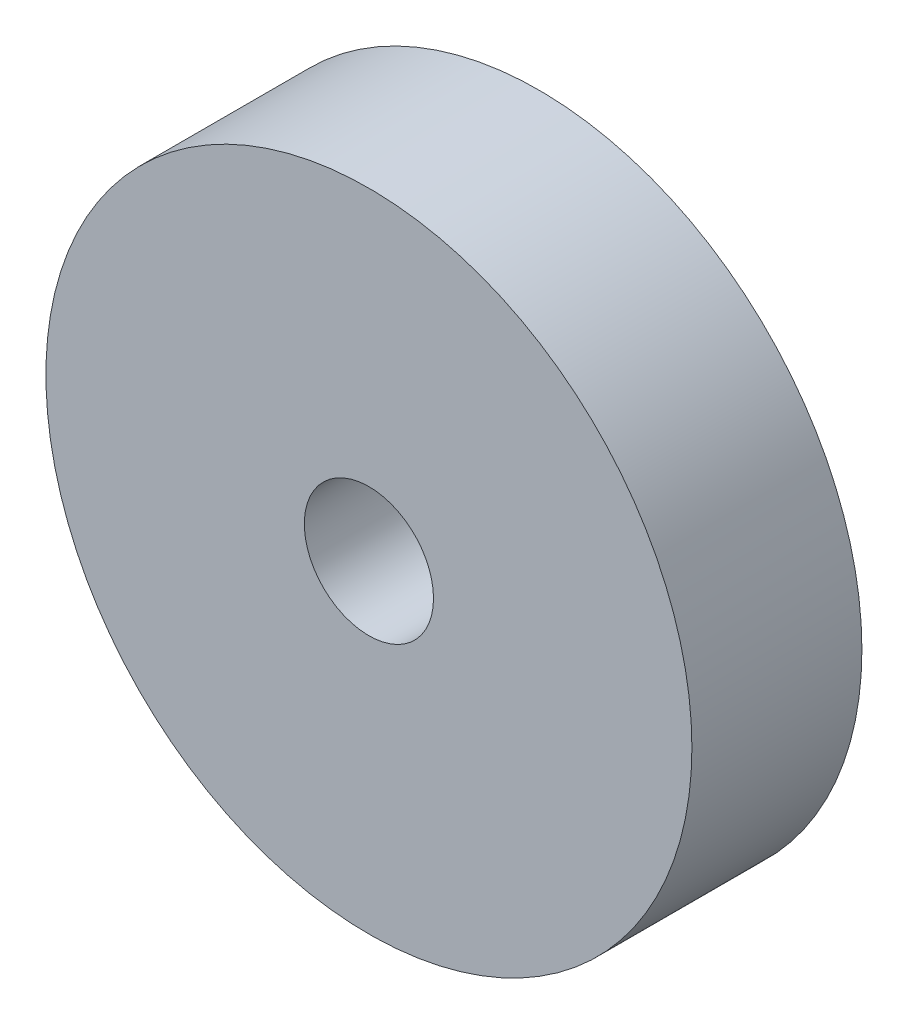
from build123d import *

# Parameters (mm, degrees)
SKETCH1_R           = 95
SKETCH1_R_2         = 19
BOSS_EXTRUDE1_DEPTH = 50


with BuildPart() as part:
    # Sketch1 → Boss-Extrude1 (new body)
    with BuildSketch(Plane.XY):
        Circle(SKETCH1_R)
        Circle(SKETCH1_R_2, mode=Mode.SUBTRACT)
    extrude(amount=BOSS_EXTRUDE1_DEPTH)


solid = part.part
